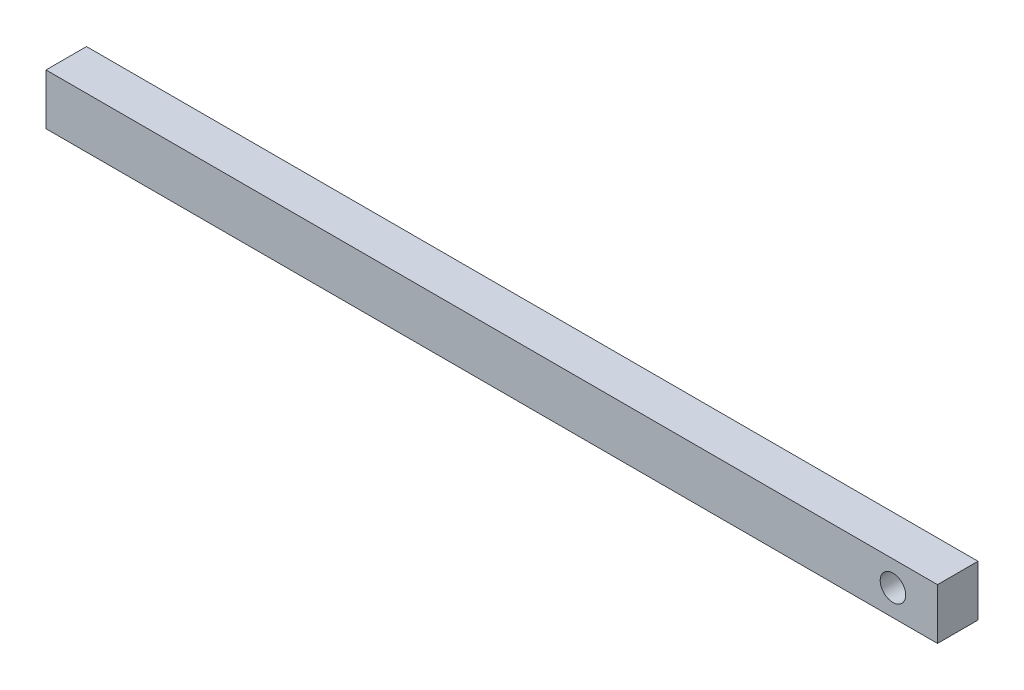
from build123d import *

# Parameters (mm, degrees)
SKETCH2_W           = 70
SKETCH2_H           = 4
BOSS_EXTRUDE1_DEPTH = 3.18
SKETCH4_R           = 1
CUT_EXTRUDE1_DEPTH  = 10


with BuildPart() as part:
    # Sketch2 → Boss-Extrude1 (new body)
    with BuildSketch(Plane.XY):
        with Locations((35, 2)):
            Rectangle(SKETCH2_W, SKETCH2_H)
    extrude(amount=BOSS_EXTRUDE1_DEPTH)

    # Sketch4 → Cut-Extrude1 (cut)
    with BuildSketch(Plane.XY.offset(3.18)):
        with Locations((66.500173303, 2.034829504)):
            Circle(SKETCH4_R)
    extrude(amount=-CUT_EXTRUDE1_DEPTH, mode=Mode.SUBTRACT)


solid = part.part
